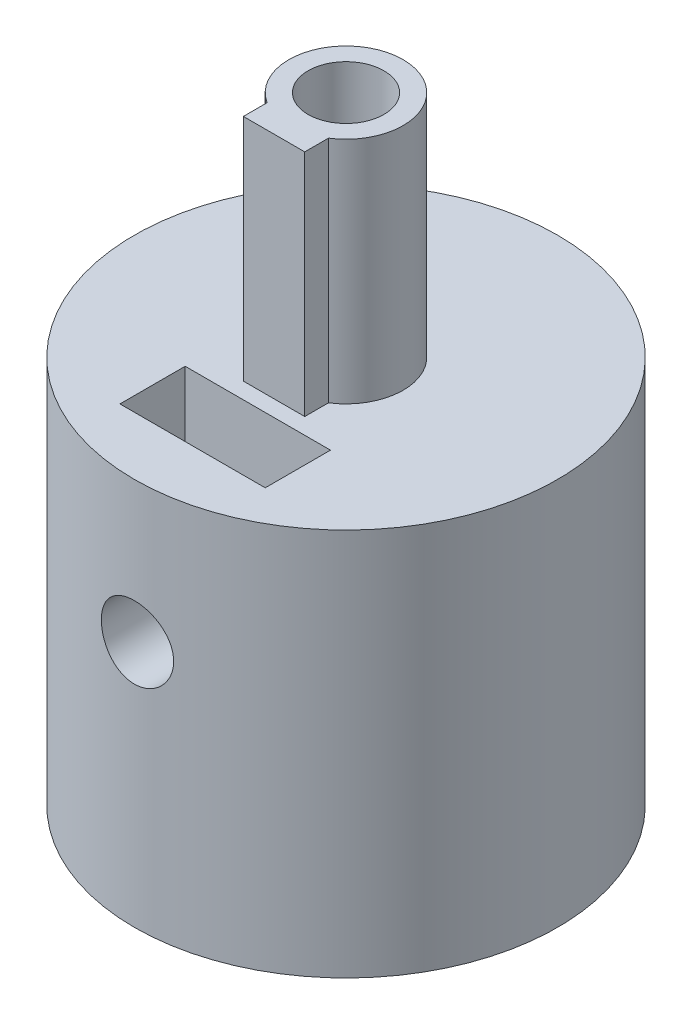
from build123d import *

# Parameters (mm, degrees)
SKETCH1_R           = 6
BOSS_EXTRUDE1_DEPTH = 10
SKETCH2_R           = 1.025
CUT_EXTRUDE1_DEPTH  = 7
SKETCH4_R           = 2.1
CUT_EXTRUDE4_DEPTH  = 11.0000001
SKETCH5_W           = 0.95
SKETCH5_H           = 7.069146706
BOSS_EXTRUDE2_DEPTH = 1.2
SKETCH7_R           = 6
BOSS_EXTRUDE3_DEPTH = 1
SKETCH8_R           = 1.62
SKETCH8_W           = 1.74
SKETCH8_H           = 0.84
BOSS_EXTRUDE4_DEPTH = 6.5
SKETCH9_R           = 1.075
CUT_EXTRUDE5_DEPTH  = 6
CUT_EXTRUDE2_START  = 2.5
CUT_EXTRUDE2_DEPTH  = 1.85


with BuildPart() as part:
    # Sketch1 → Boss-Extrude1 (new body)
    with BuildSketch(Plane(origin=(0, 0, 0), x_dir=(1, 0, 0), z_dir=(0, 1, 0))):
        Circle(SKETCH1_R)
    extrude(amount=BOSS_EXTRUDE1_DEPTH)

    # Sketch2 → Cut-Extrude1 (cut, through all)
    with BuildSketch(Plane.XY):
        with Locations((0, 7)):
            Circle(SKETCH2_R)
    extrude(amount=CUT_EXTRUDE1_DEPTH, mode=Mode.SUBTRACT)

    # Sketch4 → Cut-Extrude4 (cut, through all)
    with BuildSketch(Plane(origin=(0, 0, 0), x_dir=(1, 0, 0), z_dir=(0, 1, 0))):
        Circle(SKETCH4_R)
    extrude(amount=CUT_EXTRUDE4_DEPTH, mode=Mode.SUBTRACT)

    # Sketch5 → Boss-Extrude2 (add)
    with BuildSketch(Plane(origin=(0, 10, 0), x_dir=(1, 0, 0), z_dir=(0, 1, 0))):
        Rectangle(SKETCH5_W, SKETCH5_H)
    extrude(amount=-BOSS_EXTRUDE2_DEPTH)

    # Sketch7 → Boss-Extrude3 (add)
    with BuildSketch(Plane(origin=(0, 10, 0), x_dir=(1, 0, 0), z_dir=(0, 1, 0))):
        Circle(SKETCH7_R)
    extrude(amount=BOSS_EXTRUDE3_DEPTH)

    # Sketch8 → Boss-Extrude4 (add)
    with BuildSketch(Plane(origin=(0, 11, 0), x_dir=(1, 0, 0), z_dir=(0, 1, 0))):
        Circle(SKETCH8_R)
        with Locations((0, -1.62)):
            Rectangle(SKETCH8_W, SKETCH8_H)
    extrude(amount=BOSS_EXTRUDE4_DEPTH)

    # Sketch9 → Cut-Extrude5 (cut)
    with BuildSketch(Plane(origin=(0, 17.5, 0), x_dir=(1, 0, 0), z_dir=(0, 1, 0))):
        Circle(SKETCH9_R)
    extrude(amount=-CUT_EXTRUDE5_DEPTH, mode=Mode.SUBTRACT)

    # Sketch3 → Cut-Extrude2 (cut)
    with BuildSketch(Plane.XY.offset(CUT_EXTRUDE2_START)):
        Polygon((0, 4.621316891), (2.06, 5.810658445), (2.06, 8.189341555), (2.06, 11.363105915), (-2.06, 11.363105915), (-2.06, 8.189341555), (-2.06, 5.810658445), align=None)
    extrude(amount=CUT_EXTRUDE2_DEPTH, mode=Mode.SUBTRACT)


solid = part.part
